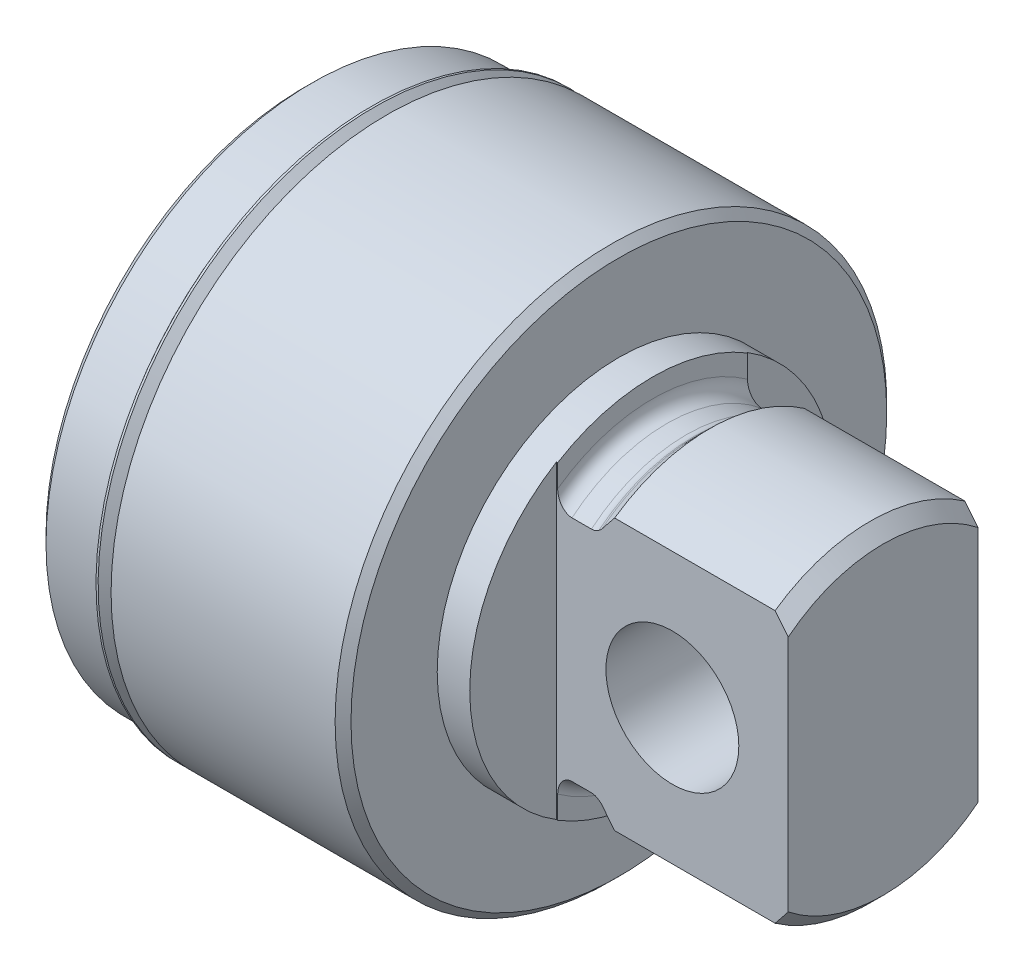
from build123d import *

# Parameters (mm, degrees)
SKETCH3_W               = 105.9434
SKETCH3_H               = 211.8868
SKETCH3_W_2             = 18.2245
SKETCH3_H_2             = 105.9434
CUT_EXTRUDE1_DEPTH      = 22.2504
CUT_EXTRUDE2_DEPTH      = 13.668375
CUT_EXTRUDE2_DEPTH_BACK = 13.668375
SKETCH5_R               = 6.38175


with BuildPart() as part:
    # Sketch1 → Revolve1 (revolve)
    with BuildSketch(Plane.XY):
        Polygon((0, 0), (0, 24.80945), (0.762, 25.57145), (5.8166, 25.57145), (6.8707, 24.51735), (7.9248, 24.51735), (7.9248, 26.48585), (29.4386, 26.48585), (30.2006, 25.72385), (30.2006, 0), align=None)
    revolve(axis=Axis((30.2006, 0, 0), (-1, 0, 0)))

    # Sketch2 → Revolve2 (revolve)
    with BuildSketch(Plane.XY):
        with BuildLine():
            Line((30.2006, 0), (30.2006, 17.44345))
            Line((30.2006, 17.44345), (33.4391, 17.44345))
            Line((33.4391, 17.44345), (33.4391, 15.62735))
            ThreePointArc((33.4391, 15.62735), (33.840832339, 14.657482339), (34.8107, 14.25575))
            Line((34.8107, 14.25575), (36.6776, 14.25575))
            ThreePointArc((36.6776, 14.25575), (37.053975321, 14.308400351), (37.401455494, 14.462309321))
            Line((37.401455494, 14.462309321), (37.647467661, 14.61516))
            Line((37.647467661, 14.61516), (38.907307661, 15.875))
            Line((38.907307661, 15.875), (54.31536, 15.875))
            Line((54.31536, 15.875), (55.5752, 14.61516))
            Line((55.5752, 14.61516), (55.5752, 0))
            Line((55.5752, 0), (30.2006, 0))
        make_face()
    revolve(axis=Axis((55.5752, 0, 0), (-1, 0, 0)))

    # Sketch3 → Cut-Extrude1 (cut)
    with BuildSketch(Plane(origin=(55.5752, 0, 0), x_dir=(0, 0, -1), z_dir=(1, 0, 0))):
        Rectangle(SKETCH3_W, SKETCH3_H)
        Rectangle(SKETCH3_W_2, SKETCH3_H_2, mode=Mode.SUBTRACT)
    extrude(amount=-CUT_EXTRUDE1_DEPTH, mode=Mode.SUBTRACT)

    # Sketch4 → Revolve3 (revolve)
    with BuildSketch(Plane.XY):
        with BuildLine():
            Line((6.477090712, 26.401681804), (7.789783697, 25.088988819))
            ThreePointArc((7.789783697, 25.088988819), (7.826981136, 24.999186258), (7.789783697, 24.909383697))
            Line((7.789783697, 24.909383697), (7.39775, 24.51735))
            Line((7.39775, 24.51735), (6.8707, 24.51735))
            Line((6.8707, 24.51735), (6.8707, 24.26335))
            Line((6.8707, 24.26335), (7.9248, 24.26335))
            Line((7.9248, 24.26335), (7.9248, 25.241340712))
            Line((7.9248, 25.241340712), (6.680290712, 26.48585))
            Line((6.680290712, 26.48585), (6.477090712, 26.48585))
            Line((6.477090712, 26.48585), (6.477090712, 26.401681804))
        make_face()
    revolve(axis=Axis((7.9248, 0, 0), (-1, 0, 0)))

    # Sketch5 → Cut-Extrude2 (cut, two sides: drawn at the far end of the back side and taken through both)
    with BuildSketch(Plane.XY.offset(-CUT_EXTRUDE2_DEPTH_BACK)):
        with Locations((44.45, 0)):
            Circle(SKETCH5_R)
    extrude(amount=CUT_EXTRUDE2_DEPTH + CUT_EXTRUDE2_DEPTH_BACK, mode=Mode.SUBTRACT)

    # Sketch6 → Cut-Revolve1 (revolve, cut)
    with BuildSketch(Plane.XY):
        Polygon((0, 0), (0, 20.5994), (0.762, 19.8374), (3.175, 19.8374), (3.175, 16.59255), (3.937, 15.83055), (12.7, 15.83055), (12.7, 0), align=None)
    revolve(axis=Axis((12.7, 0, 0), (-1, 0, 0)), mode=Mode.SUBTRACT)


solid = part.part
